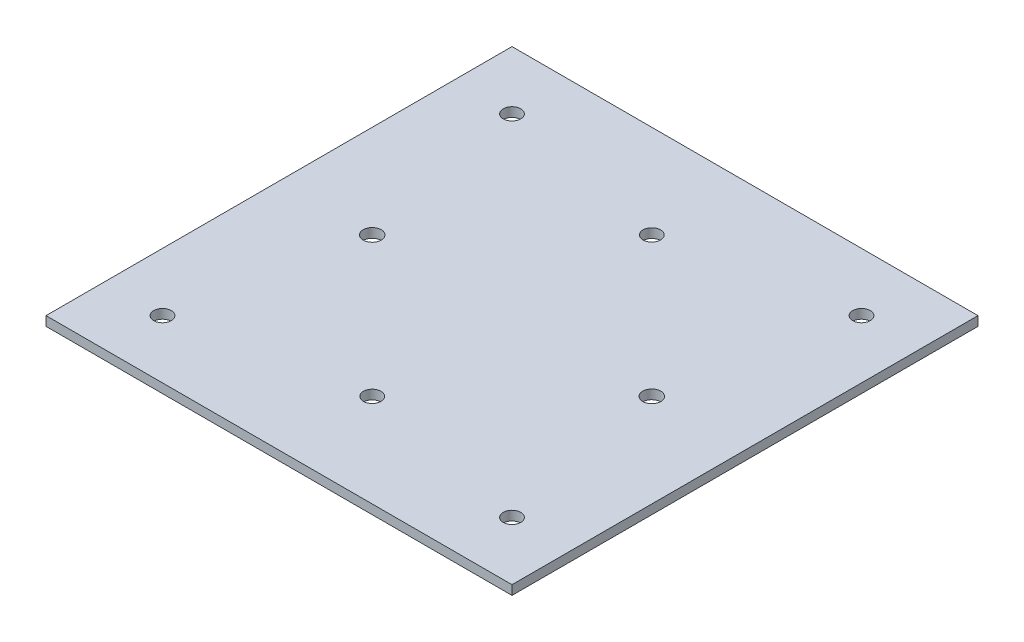
from build123d import *

# Parameters (mm, degrees)
SKETCH2_W           = 96
SKETCH2_H           = 96
BOSS_EXTRUDE1_DEPTH = 1.6
SKETCH3_R           = 1.55
SKETCH3_R_2         = 1.505
CUT_EXTRUDE1_DEPTH  = 2.6
SKETCH4_OUTSIDE_W   = 125.154
SKETCH4_OUTSIDE_H   = 125.154
SKETCH4_OUTSIDE_W_2 = 80
SKETCH4_OUTSIDE_H_2 = 80
CUT_EXTRUDE2_DEPTH  = 10


with BuildPart() as part:
    # Sketch2 → Boss-Extrude1 (new body)
    with BuildSketch(Plane(origin=(0, 0, 0), x_dir=(1, 0, 0), z_dir=(0, 1, 0))):
        with Locations((48, 48)):
            Rectangle(SKETCH2_W, SKETCH2_H)
    extrude(amount=BOSS_EXTRUDE1_DEPTH)

    # Sketch3 → Cut-Extrude1 (cut, through all)
    with BuildSketch(Plane(origin=(0, 1.6, 0), x_dir=(1, 0, 0), z_dir=(0, 1, 0))):
        with Locations((24, 48)):
            Circle(SKETCH3_R)
        with Locations((72, 48)):
            Circle(SKETCH3_R)
        with Locations((48, 72)):
            Circle(SKETCH3_R_2)
        with Locations((48, 24)):
            Circle(SKETCH3_R_2)
        with Locations((18, 78)):
            Circle(SKETCH3_R_2)
        with Locations((78, 78)):
            Circle(SKETCH3_R_2)
        with Locations((78, 18)):
            Circle(SKETCH3_R_2)
        with Locations((18, 18)):
            Circle(SKETCH3_R_2)
    extrude(amount=-CUT_EXTRUDE1_DEPTH, mode=Mode.SUBTRACT)

    # Sketch4 outside → Cut-Extrude2 (cut)
    with BuildSketch(Plane(origin=(0, 1.6, 0), x_dir=(1, 0, 0), z_dir=(0, 1, 0))):
        with Locations((48, 48)):
            Rectangle(SKETCH4_OUTSIDE_W, SKETCH4_OUTSIDE_H)
        with Locations((48, 48)):
            Rectangle(SKETCH4_OUTSIDE_W_2, SKETCH4_OUTSIDE_H_2, mode=Mode.SUBTRACT)
    extrude(amount=-CUT_EXTRUDE2_DEPTH, mode=Mode.SUBTRACT)


solid = part.part
